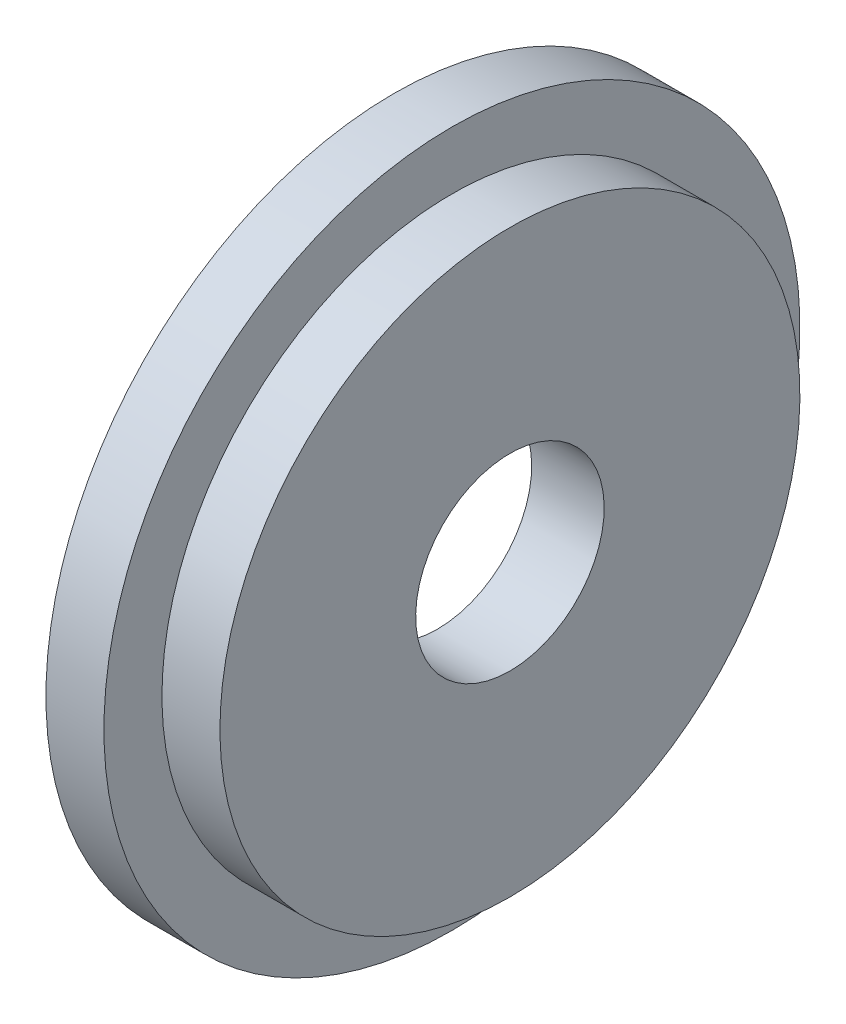
from build123d import *


with BuildPart() as part:
    # Эскиз1 → Повернуть1 (revolve)
    with BuildSketch(Plane.XY):
        Polygon((-4.480196097, 8.5), (-4.480196097, 12), (-2.480196097, 12), (-2.480196097, 10), (-0.480196097, 10), (-0.480196097, 3.25), (-2.980196097, 3.25), (-2.980196097, 8.5), align=None)
    revolve(axis=Axis((-4.480196097, 0, 0), (1, 0, 0)))


solid = part.part
